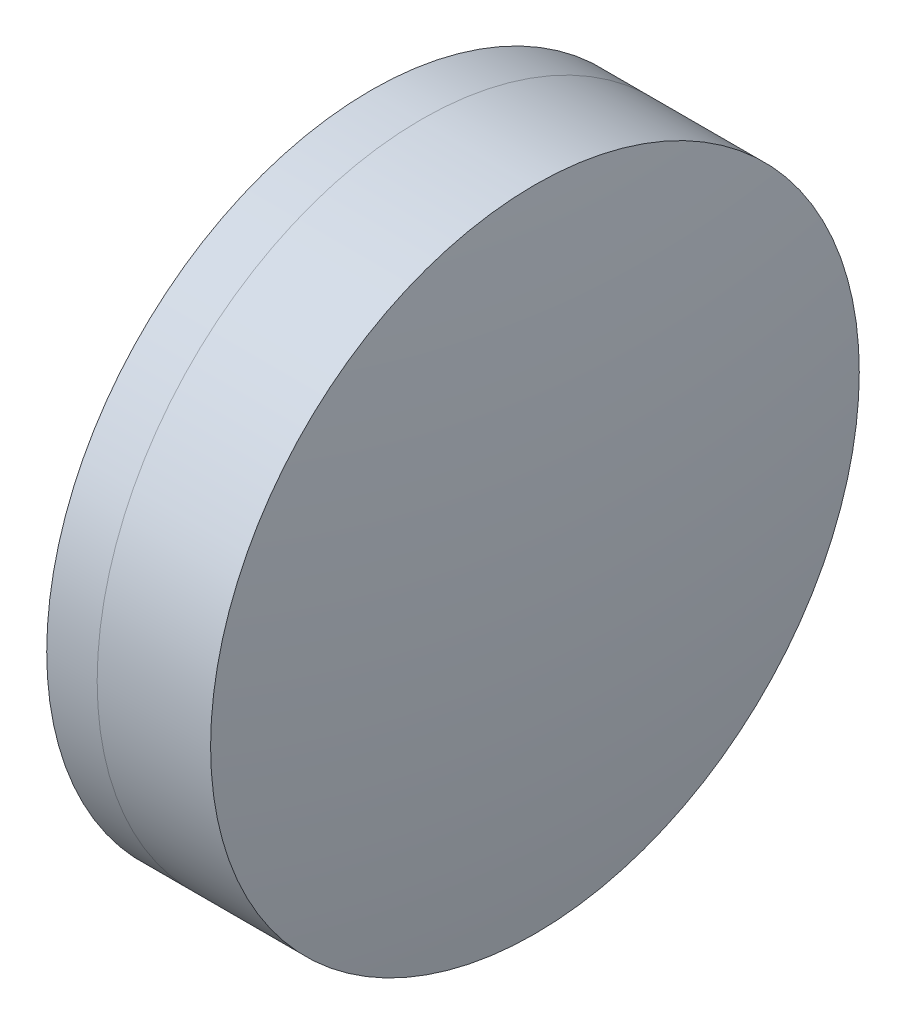
from build123d import *


with BuildPart() as part:
    # 草图1 one side → 旋转1 (revolve)
    with BuildSketch(Plane(origin=(0, 0, 0), x_dir=(1, 0, 0), z_dir=(0, 1, 0)), mode=Mode.PRIVATE) as revolve_1_sk:
        with BuildLine():
            ThreePointArc((39.618581864, 12.5), (38.149385723, 6.326591243), (37.655668974, 0))
            Line((37.655668974, 0), (44.345668974, 0))
            ThreePointArc((44.345668974, 0), (43.641565886, 6.403002575), (41.562906333, 12.5))
            Line((41.562906333, 12.5), (39.618581864, 12.5))
        make_face()
    revolve(revolve_1_sk.sketch.rotate(Axis((-9.702612178, 0, 0), (1, 0, 0)), 180), axis=Axis((-9.702612178, 0, 0), (1, 0, 0)))  # turned: the seam where the file's is


with BuildPart() as body_2:
    # 草图2 one side → 旋转3 (revolve)
    with BuildSketch(Plane(origin=(0, 0, 0), x_dir=(1, 0, 0), z_dir=(0, 1, 0)), mode=Mode.PRIVATE) as revolve_3_sk:
        with BuildLine():
            Line((45.933835452, 12.5), (41.562906333, 12.5))
            ThreePointArc((41.562906333, 12.5), (43.641565886, 6.403002575), (44.345668974, 0))
            Line((44.345668974, 0), (46.865668974, 0))
            ThreePointArc((46.865668974, 0), (46.63238784, 6.267342214), (45.933835452, 12.5))
        make_face()
    revolve(revolve_3_sk.sketch.rotate(Axis((-0.551919993, 0, 0), (1, 0, 0)), 180), axis=Axis((-0.551919993, 0, 0), (1, 0, 0)))  # turned: the seam where the file's is


solid = Compound([part.part, body_2.part])
